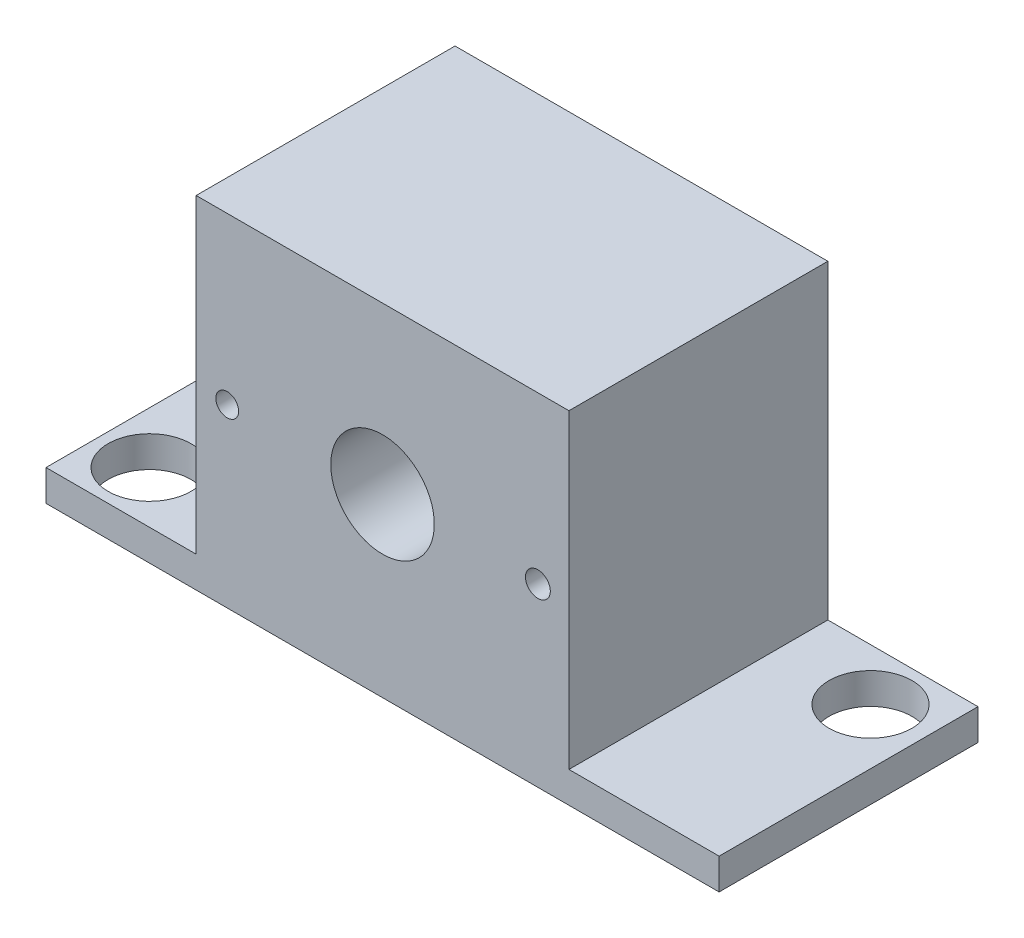
from build123d import *

# Parameters (mm, degrees)
SKETCH1_W           = 65
SKETCH1_H           = 25
SKETCH1_R           = 4
BOSS_EXTRUDE1_DEPTH = 3
SKETCH2_W           = 36
SKETCH2_H           = 30
BOSS_EXTRUDE2_DEPTH = 25
CUT_EXTRUDE1_DEPTH  = 5
SKETCH4_R           = 5
CUT_EXTRUDE2_DEPTH  = 21
SKETCH6_R           = 1.2
SKETCH6_R_2         = 1.1
CUT_EXTRUDE4_DEPTH  = 26


with BuildPart() as part:
    # Sketch1 → Boss-Extrude1 (new body)
    with BuildSketch(Plane(origin=(0, 0, 0), x_dir=(1, 0, 0), z_dir=(0, 1, 0))):
        Rectangle(SKETCH1_W, SKETCH1_H)
        with Locations((-27.5, -7.5)):
            Circle(SKETCH1_R, mode=Mode.SUBTRACT)
        with Locations((27.119741523, 7.5)):
            Circle(SKETCH1_R, mode=Mode.SUBTRACT)
    extrude(amount=BOSS_EXTRUDE1_DEPTH)

    # Sketch2 → Boss-Extrude2 (add)
    with BuildSketch(Plane(origin=(0, 0, -12.5), x_dir=(-1, 0, 0), z_dir=(0, 0, -1))):
        with Locations((0, 18)):
            Rectangle(SKETCH2_W, SKETCH2_H)
    extrude(amount=-BOSS_EXTRUDE2_DEPTH)

    # Sketch3 → Cut-Extrude1 (cut)
    with BuildSketch(Plane(origin=(0, 0, -12.5), x_dir=(-1, 0, 0), z_dir=(0, 0, -1))):
        with BuildLine():
            Line((-15, 30), (15, 30))
            Line((15, 30), (15, 19.5))
            ThreePointArc((15, 19.5), (12.5, 17), (15, 14.5))
            Line((15, 14.5), (15, 4))
            Line((15, 4), (-15, 4))
            Line((-15, 4), (-15, 14.5))
            ThreePointArc((-15, 14.5), (-12.5, 17), (-15, 19.5))
            Line((-15, 19.5), (-15, 30))
        make_face()
    extrude(amount=-CUT_EXTRUDE1_DEPTH, mode=Mode.SUBTRACT)

    # Sketch4 → Cut-Extrude2 (cut, through all)
    with BuildSketch(Plane(origin=(0, 0, -7.5), x_dir=(-1, 0, 0), z_dir=(0, 0, -1))):
        with Locations((0, 17)):
            Circle(SKETCH4_R)
    extrude(amount=-CUT_EXTRUDE2_DEPTH, mode=Mode.SUBTRACT)

    # Sketch6 → Cut-Extrude4 (cut, through all)
    with BuildSketch(Plane(origin=(0, 0, -12.5), x_dir=(-1, 0, 0), z_dir=(0, 0, -1))):
        with Locations((-15, 17)):
            Circle(SKETCH6_R)
        with Locations((15, 17)):
            Circle(SKETCH6_R_2)
    extrude(amount=-CUT_EXTRUDE4_DEPTH, mode=Mode.SUBTRACT)


solid = part.part
